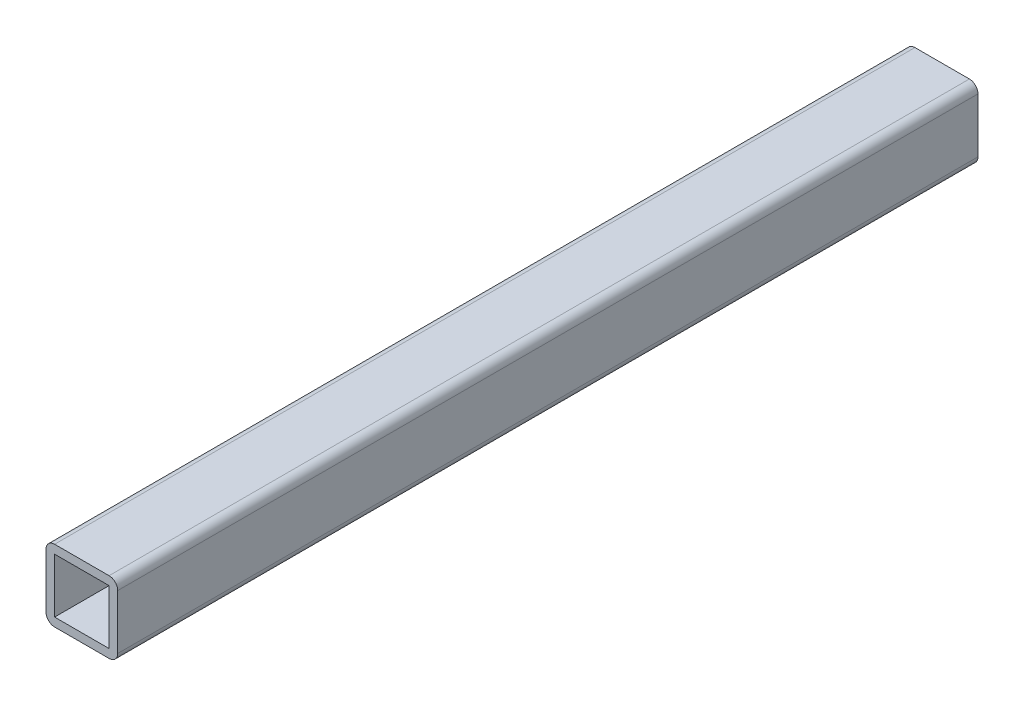
from build123d import *

# Parameters (mm, degrees)
SKETCH1_W           = 19
SKETCH1_H           = 19
BOSS_EXTRUDE1_DEPTH = 300


with BuildPart() as part:
    # Sketch1 → Boss-Extrude1 (new body)
    with BuildSketch(Plane.XY):
        with BuildLine():
            Line((-9.5, -12.5), (9.5, -12.5))
            ThreePointArc((9.5, -12.5), (11.621320344, -11.621320344), (12.5, -9.5))
            Line((12.5, -9.5), (12.5, 9.5))
            ThreePointArc((12.5, 9.5), (11.621320344, 11.621320344), (9.5, 12.5))
            Line((9.5, 12.5), (-9.5, 12.5))
            ThreePointArc((-9.5, 12.5), (-11.621320344, 11.621320344), (-12.5, 9.5))
            Line((-12.5, 9.5), (-12.5, -9.5))
            ThreePointArc((-12.5, -9.5), (-11.621320344, -11.621320344), (-9.5, -12.5))
        make_face()
        Rectangle(SKETCH1_W, SKETCH1_H, mode=Mode.SUBTRACT)
    extrude(amount=BOSS_EXTRUDE1_DEPTH)


solid = part.part
